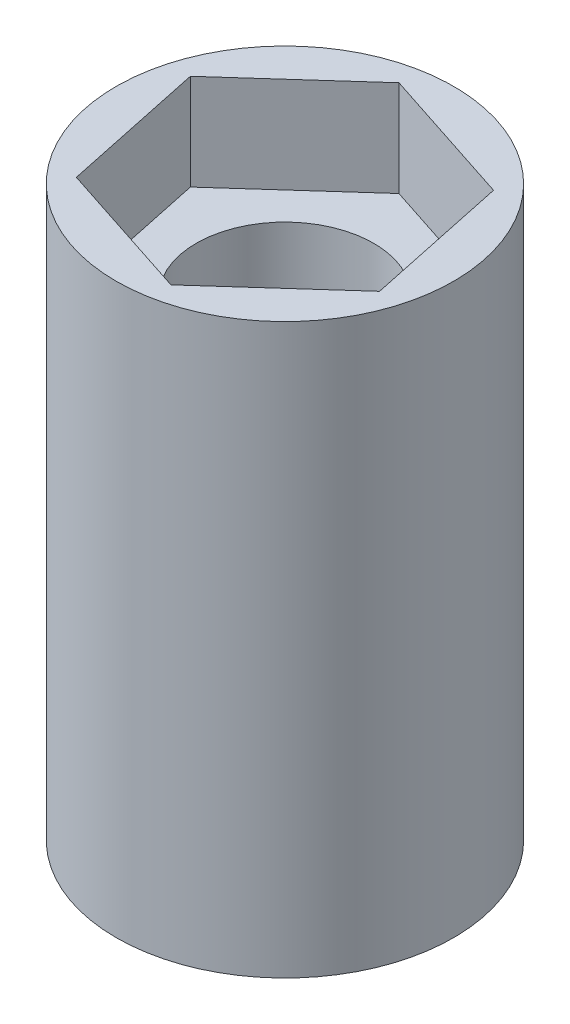
from build123d import *

# Parameters (mm, degrees)
SKIZZE1_R                       = 4.75
SKIZZE1_R_2                     = 2.5
AUFSATZ_LINEAR_AUSTRAGEN1_DEPTH = 16
SCHNITT_LINEAR_AUSTRAGEN1_DEPTH = 2.7


with BuildPart() as part:
    # Skizze1 → Aufsatz-Linear austragen1 (new body)
    with BuildSketch(Plane(origin=(0, 0, 0), x_dir=(1, 0, 0), z_dir=(0, 1, 0))):
        Circle(SKIZZE1_R)
        Circle(SKIZZE1_R_2, mode=Mode.SUBTRACT)
    extrude(amount=AUFSATZ_LINEAR_AUSTRAGEN1_DEPTH)

    # Skizze2 → Schnitt-Linear austragen1 (cut)
    with BuildSketch(Plane(origin=(0, 16, 0), x_dir=(1, 0, 0), z_dir=(0, 1, 0))):
        Polygon((3.092911693, 2.777390369), (-0.858834769, 4.067235282), (-3.951746462, 1.289844914), (-3.092911693, -2.777390369), (0.858834769, -4.067235282), (3.951746462, -1.289844914), align=None)
    extrude(amount=-SCHNITT_LINEAR_AUSTRAGEN1_DEPTH, mode=Mode.SUBTRACT)


solid = part.part
